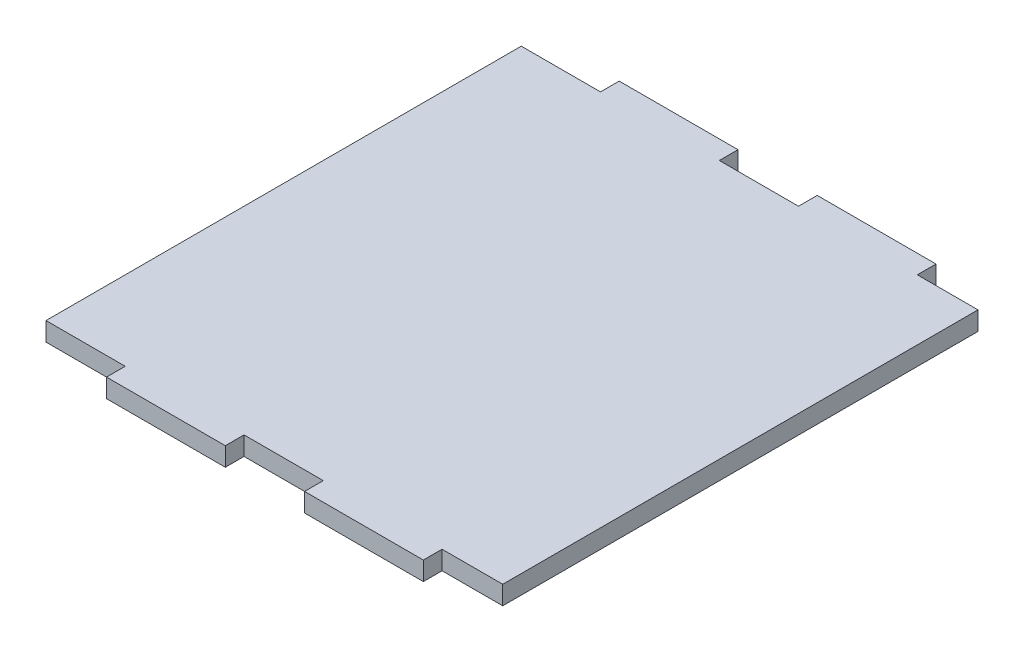
from build123d import *

# Parameters (mm, degrees)
BOSS_EXTRUDE1_DEPTH = 3


with BuildPart() as part:
    # Sketch1 → Boss-Extrude1 (new body)
    with BuildSketch(Plane(origin=(0, 0, 0), x_dir=(1, 0, 0), z_dir=(0, 1, 0))):
        Polygon((-25.4, 41.1), (-6.35, 41.1), (-6.35, 38.1), (6.35, 38.1), (6.35, 41.1), (25.4, 41.1), (25.4, 38.1), (35.127525217, 38.1), (35.127525217, -38.1), (25.4, -38.1), (25.4, -41.1), (6.35, -41.1), (6.35, -38.1), (-6.35, -38.1), (-6.35, -41.1), (-25.4, -41.1), (-25.4, -38.1), (-38.1, -38.1), (-38.1, 38.1), (-25.4, 38.1), align=None)
    extrude(amount=BOSS_EXTRUDE1_DEPTH)


solid = part.part
